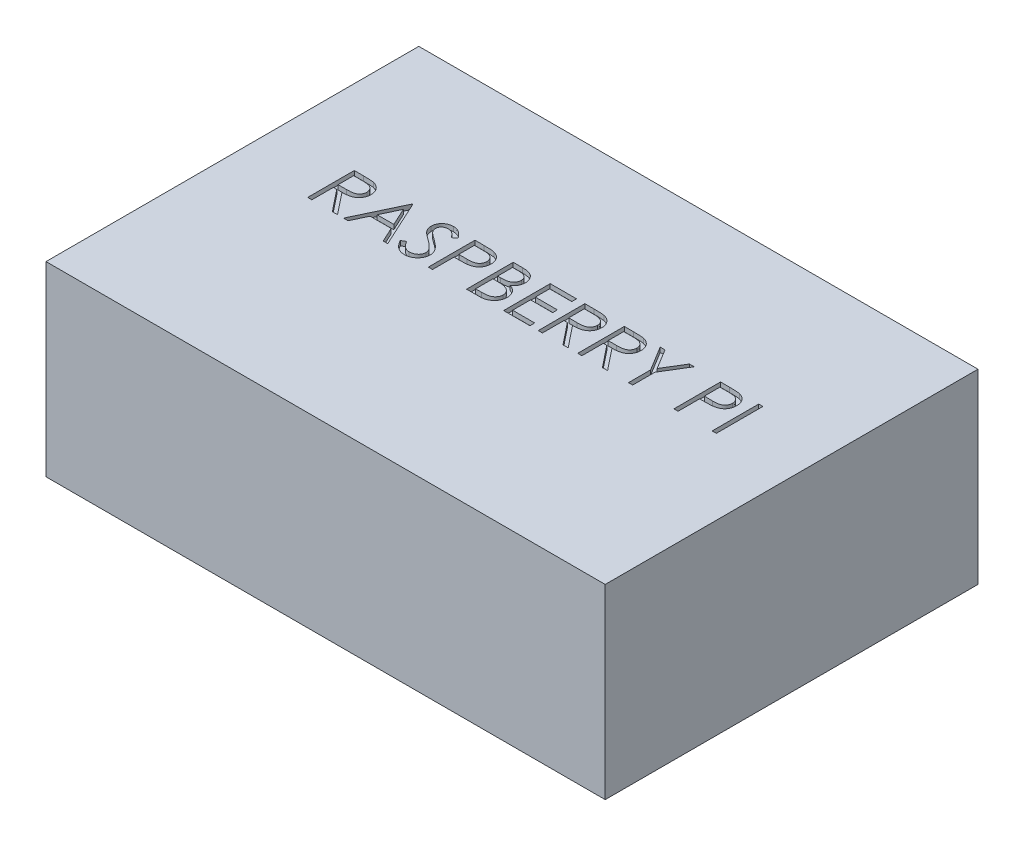
from build123d import *

# Parameters (mm, degrees)
SKETCH1_W           = 120
SKETCH1_H           = 80
BOSS_EXTRUDE1_DEPTH = 40
SKETCH2_W           = 0.897435897
SKETCH2_H           = 10
CUT_EXTRUDE1_DEPTH  = 1


with BuildPart() as part:
    # Sketch1 → Boss-Extrude1 (new body)
    with BuildSketch(Plane(origin=(0, 0, 0), x_dir=(1, 0, 0), z_dir=(0, 1, 0))):
        with Locations((60, 40)):
            Rectangle(SKETCH1_W, SKETCH1_H)
    extrude(amount=BOSS_EXTRUDE1_DEPTH)

    # Sketch2 → Cut-Extrude1 (cut)
    with BuildSketch(Plane(origin=(0, 40, 0), x_dir=(1, 0, 0), z_dir=(0, 1, 0))):
        with BuildLine():
            Line((16.153846154, 50), (18.155048077, 50))
            add(Edge.make_bspline(
                [(18.155048077, 50), (18.288594158, 49.999555469), (18.545017428, 49.998701919), (18.912369629, 49.993942596), (19.246161335, 49.98030158), (19.546218019, 49.96856277), (19.812534176, 49.947157224), (20.045926435, 49.926698232), (20.245319856, 49.899916344), (20.366022289, 49.875043707), (20.420673077, 49.863782051)],
                knots=[0, 0, 0, 0, 1.410062039, 2.707475311, 3.878576406, 4.937260626, 5.877586885, 6.699081471, 7.410979367, 8, 8, 8, 8], degree=3))
            add(Edge.make_bspline(
                [(20.420673077, 49.863782051), (20.49383486, 49.845705579), (20.638597687, 49.809938254), (20.847026447, 49.734339395), (21.045638801, 49.646854753), (21.233609728, 49.544101266), (21.409997703, 49.425316181), (21.576621448, 49.292550117), (21.734237058, 49.146529529), (21.876470287, 48.983572839), (22.010581863, 48.812611383), (22.123692225, 48.627743506), (22.221196452, 48.434424856), (22.298826501, 48.230689377), (22.361334997, 48.018512886), (22.405409966, 47.795973467), (22.431841931, 47.564084967), (22.434532947, 47.405919513), (22.435897436, 47.325721154)],
                knots=[0, 0, 0, 0, 1.027469482, 2.033020251, 3.019912614, 3.986113645, 4.951240523, 5.91722682, 6.890402269, 7.87763091, 8.8651537, 9.85103654, 10.82876324, 11.815024772, 12.821070561, 13.842952187, 14.906261191, 16, 16, 16, 16], degree=3))
            add(Edge.make_bspline(
                [(22.435897436, 47.325721154), (22.431700298, 47.192477998), (22.423510596, 46.93248609), (22.347153157, 46.555169286), (22.222077386, 46.203199815), (22.049725132, 45.87702085), (21.830240916, 45.582990434), (21.566455798, 45.324731991), (21.258222623, 45.108617955), (20.97128172, 44.958752798), (20.717812578, 44.862773059), (20.50914597, 44.795240606), (20.281526034, 44.743063562), (20.03713365, 44.696320328), (19.774951777, 44.661029773), (19.495608807, 44.63518236), (19.198905517, 44.619027935), (18.995079604, 44.616622207), (18.890224359, 44.615384615)],
                knots=[0, 0, 0, 0, 1.260483769, 2.459530307, 3.627416485, 4.787058657, 5.939039949, 7.08810263, 8.267026773, 9.491475466, 10.141966685, 10.831826277, 11.566392101, 12.351337768, 13.187381173, 14.07005841, 15.007169909, 16, 16, 16, 16], degree=3))
            Line((18.890224359, 44.615384615), (22.564102564, 40))
            Line((22.564102564, 40), (21.454326923, 40))
            Line((21.454326923, 40), (17.780448718, 44.615384615))
            Line((17.780448718, 44.615384615), (17.051282051, 44.615384615))
            Line((17.051282051, 44.615384615), (17.051282051, 40))
            Line((17.051282051, 40), (16.153846154, 40))
            Line((16.153846154, 40), (16.153846154, 50))
        make_face()
        with BuildLine():
            Line((17.051282051, 48.974358974), (17.051282051, 45.641025641))
            Line((17.051282051, 45.641025641), (18.882211538, 45.627003205))
            add(Edge.make_bspline(
                [(18.882211538, 45.627003205), (18.967697364, 45.626965386), (19.133393241, 45.626892082), (19.373109427, 45.638302871), (19.596309746, 45.651283781), (19.802140466, 45.671139054), (19.990693539, 45.69672783), (20.161874719, 45.728736356), (20.315963439, 45.766027964), (20.495673549, 45.823746895), (20.696349353, 45.915192661), (20.914439238, 46.048236943), (21.100160203, 46.215577284), (21.257068381, 46.406930015), (21.383152471, 46.617319298), (21.472044055, 46.84422321), (21.528451033, 47.08191349), (21.53510402, 47.245279512), (21.538461538, 47.327724359)],
                knots=[0, 0, 0, 0, 1.146690395, 2.22261258, 3.21895312, 4.145990853, 4.996080663, 5.770904154, 6.481378293, 7.121626537, 8.300444488, 9.431385265, 10.535395872, 11.636531494, 12.74115979, 13.810798291, 14.895190096, 16, 16, 16, 16], degree=3))
            add(Edge.make_bspline(
                [(21.538461538, 47.327724359), (21.535026907, 47.408143141), (21.52822072, 47.567503823), (21.47265281, 47.800806424), (21.378683149, 48.02099771), (21.252048183, 48.227181953), (21.097764884, 48.414341198), (20.916856847, 48.574475921), (20.714270575, 48.706617249), (20.524924294, 48.791058336), (20.355683687, 48.842829345), (20.208741801, 48.879261242), (20.042709008, 48.908531153), (19.856779126, 48.931982755), (19.651745895, 48.952139739), (19.426572607, 48.96571625), (19.182753234, 48.973755861), (19.013762002, 48.974153258), (18.926282051, 48.974358974)],
                knots=[0, 0, 0, 0, 1.101028733, 2.181837193, 3.264309656, 4.369019818, 5.486613113, 6.575447106, 7.666700264, 8.788928104, 9.402425223, 10.0903467, 10.862060571, 11.710948788, 12.657782767, 13.684531032, 14.801375019, 16, 16, 16, 16], degree=3))
            Line((18.926282051, 48.974358974), (17.051282051, 48.974358974))
        make_face(mode=Mode.SUBTRACT)
        Polygon((28.717948718, 50), (33.333333333, 40), (32.357772436, 40), (30.879407051, 43.205128205), (26.346153846, 43.205128205), (24.827724359, 40), (23.846153846, 40), (28.58974359, 50), align=None)
        Polygon((28.643830128, 48.048878205), (26.834935897, 44.230769231), (30.406650641, 44.230769231), align=None, mode=Mode.SUBTRACT)
        with BuildLine():
            Line((34.102564103, 41.929086538), (34.947916667, 42.435897436))
            add(Edge.make_bspline(
                [(34.947916667, 42.435897436), (35.026540202, 42.304284907), (35.177179861, 42.052120382), (35.428469458, 41.711383124), (35.688849204, 41.421776961), (35.9602473, 41.184986654), (36.241007152, 40.998561264), (36.532961591, 40.866554887), (36.835126765, 40.784223529), (37.040766255, 40.774223282), (37.143429487, 40.769230769)],
                knots=[0, 0, 0, 0, 1.272034388, 2.437168799, 3.508375237, 4.49857839, 5.41946034, 6.295179144, 7.148887113, 8, 8, 8, 8], degree=3))
            add(Edge.make_bspline(
                [(37.143429487, 40.769230769), (37.231106231, 40.771672691), (37.404925583, 40.776513806), (37.660817706, 40.823030383), (37.909337141, 40.894493608), (38.14536182, 40.996839127), (38.365635004, 41.120663372), (38.558796991, 41.270223879), (38.725785886, 41.437670181), (38.862383356, 41.624477766), (38.967183457, 41.825383905), (39.047732224, 42.031600909), (39.092432434, 42.246368247), (39.099166016, 42.390969569), (39.102564103, 42.463942308)],
                knots=[0, 0, 0, 0, 1.095163259, 2.171163733, 3.241058638, 4.321873601, 5.38011039, 6.391990106, 7.366004449, 8.327778327, 9.272591725, 10.192022065, 11.087607919, 12, 12, 12, 12], degree=3))
            add(Edge.make_bspline(
                [(39.102564103, 42.463942308), (39.098351786, 42.547201878), (39.089788763, 42.716456419), (39.017413105, 42.966169713), (38.903558114, 43.213291342), (38.79852199, 43.3661521), (38.743990385, 43.445512821)],
                knots=[0, 0, 0, 0, 0.938893495, 1.908633276, 2.914225137, 4, 4, 4, 4], degree=3))
            add(Edge.make_bspline(
                [(38.743990385, 43.445512821), (38.699217201, 43.502789459), (38.605221503, 43.623034598), (38.44362861, 43.802020985), (38.254011141, 43.986645039), (38.042858127, 44.183956631), (37.802477873, 44.384778907), (37.54039926, 44.598688272), (37.249931092, 44.817549921), (37.046218244, 44.96432868), (36.941105769, 45.040064103)],
                knots=[0, 0, 0, 0, 0.722233717, 1.516239348, 2.393582979, 3.351407094, 4.387010283, 5.505090956, 6.712668013, 8, 8, 8, 8], degree=3))
            add(Edge.make_bspline(
                [(36.941105769, 45.040064103), (36.835894352, 45.115002924), (36.634738133, 45.258280245), (36.353427898, 45.470921057), (36.101872289, 45.665332112), (35.881189385, 45.843343575), (35.691476251, 46.004979589), (35.531237934, 46.148687987), (35.404556342, 46.278355303), (35.334111826, 46.362473423), (35.302483974, 46.400240385)],
                knots=[0, 0, 0, 0, 1.452282411, 2.77665338, 3.964542531, 5.026858415, 5.96415736, 6.766646006, 7.446254459, 8, 8, 8, 8], degree=3))
            add(Edge.make_bspline(
                [(35.302483974, 46.400240385), (35.258276702, 46.45910049), (35.171337169, 46.574856786), (35.056577153, 46.755784951), (34.959036688, 46.940994281), (34.882572882, 47.130982466), (34.818183685, 47.323082262), (34.774875312, 47.519800107), (34.747757035, 47.720253303), (34.74497993, 47.855149019), (34.743589744, 47.922676282)],
                knots=[0, 0, 0, 0, 1.068054152, 2.10047183, 3.106115577, 4.101338837, 5.06977816, 6.043150881, 7.020423561, 8, 8, 8, 8], degree=3))
            add(Edge.make_bspline(
                [(34.743589744, 47.922676282), (34.747318912, 48.028475638), (34.754697541, 48.237812963), (34.817099019, 48.543615336), (34.915593001, 48.835576528), (35.053578395, 49.110806053), (35.231456546, 49.362137427), (35.437302187, 49.592461675), (35.682477862, 49.786086196), (35.951485357, 49.955263505), (36.245932134, 50.087680435), (36.554477572, 50.187568949), (36.877612064, 50.244166828), (37.096478163, 50.252289014), (37.207532051, 50.256410256)],
                knots=[0, 0, 0, 0, 1.005424448, 1.989358655, 2.955360095, 3.929531133, 4.905563448, 5.876582895, 6.856512386, 7.866279853, 8.892233794, 9.918561126, 10.94386622, 12, 12, 12, 12], degree=3))
            add(Edge.make_bspline(
                [(37.207532051, 50.256410256), (37.325372338, 50.252345823), (37.559719057, 50.244262963), (37.904431102, 50.173984302), (38.236318863, 50.057696668), (38.503299619, 49.925729074), (38.712250366, 49.793925029), (38.871601031, 49.673868388), (39.033079462, 49.535653792), (39.19798819, 49.378913089), (39.363532931, 49.202208086), (39.532171366, 49.006748975), (39.704297849, 48.793730244), (39.815028878, 48.641660242), (39.871794872, 48.563701923)],
                knots=[0, 0, 0, 0, 1.286793592, 2.559021753, 3.825965368, 5.121522368, 5.803751409, 6.523245864, 7.299691795, 8.125521123, 9.008227632, 9.944561021, 10.946284179, 12, 12, 12, 12], degree=3))
            Line((39.871794872, 48.563701923), (39.060496795, 47.948717949))
            add(Edge.make_bspline(
                [(39.060496795, 47.948717949), (39.011508416, 48.011828493), (38.917168253, 48.133364645), (38.773941148, 48.303568404), (38.638945011, 48.45904406), (38.505943869, 48.594087282), (38.381962065, 48.716093378), (38.261627658, 48.820549826), (38.146672369, 48.908480098), (38.00176691, 49.002318841), (37.819716286, 49.095337423), (37.59118904, 49.174049074), (37.352371111, 49.221349251), (37.189715021, 49.227603216), (37.107371795, 49.230769231)],
                knots=[0, 0, 0, 0, 1.181633172, 2.275549214, 3.290209073, 4.226197932, 5.078386478, 5.862611352, 6.581680152, 7.217281963, 8.414376989, 9.595101626, 10.782541182, 12, 12, 12, 12], degree=3))
            add(Edge.make_bspline(
                [(37.107371795, 49.230769231), (37.004067445, 49.227307231), (36.804854738, 49.22063109), (36.522025492, 49.147716847), (36.267471421, 49.032911531), (36.048749806, 48.872011594), (35.866644157, 48.681380186), (35.734914275, 48.462012029), (35.655628091, 48.219776593), (35.645953006, 48.050800432), (35.641025641, 47.96474359)],
                knots=[0, 0, 0, 0, 1.14458467, 2.207223713, 3.21896685, 4.227309161, 5.202851033, 6.127160689, 7.046193047, 8, 8, 8, 8], degree=3))
            add(Edge.make_bspline(
                [(35.641025641, 47.96474359), (35.64214886, 47.911167937), (35.644397135, 47.803929024), (35.675753699, 47.64549639), (35.716037496, 47.487463992), (35.779873587, 47.330542326), (35.868003026, 47.171987015), (35.9837321, 47.009067765), (36.12948442, 46.840348597), (36.241133027, 46.730613243), (36.300080128, 46.672676282)],
                knots=[0, 0, 0, 0, 0.858281714, 1.717966888, 2.583508476, 3.4729293, 4.427298488, 5.488583878, 6.674047936, 8, 8, 8, 8], degree=3))
            add(Edge.make_bspline(
                [(36.300080128, 46.672676282), (36.321969764, 46.653141923), (36.373974527, 46.606732756), (36.4690486, 46.530754811), (36.594599453, 46.437032605), (36.747348599, 46.321068843), (36.930112489, 46.18655038), (37.142911221, 46.035197203), (37.383372744, 45.862095891), (37.554006789, 45.741074346), (37.644230769, 45.677083333)],
                knots=[0, 0, 0, 0, 0.420754252, 0.999615792, 1.744751191, 2.668019286, 3.750313428, 4.999500688, 6.413464383, 8, 8, 8, 8], degree=3))
            add(Edge.make_bspline(
                [(37.644230769, 45.677083333), (37.75276195, 45.59810802), (37.96291754, 45.445183272), (38.261939197, 45.215424187), (38.533064363, 44.990716276), (38.777244944, 44.772494542), (38.996893254, 44.562414276), (39.189572456, 44.357948047), (39.357245828, 44.160560696), (39.537757881, 43.907496194), (39.722208794, 43.596693096), (39.880613101, 43.215898129), (39.980494094, 42.833622928), (39.993555566, 42.576689109), (40, 42.449919872)],
                knots=[0, 0, 0, 0, 1.163667725, 2.253281268, 3.268753668, 4.215851969, 5.092017293, 5.902905408, 6.650798638, 7.335211899, 8.59617414, 9.77448103, 10.901945474, 12, 12, 12, 12], degree=3))
            add(Edge.make_bspline(
                [(40, 42.449919872), (39.998122463, 42.3602674), (39.994403848, 42.182703447), (39.95165838, 41.921974656), (39.889030765, 41.6687436), (39.794638668, 41.426140421), (39.679429645, 41.189726814), (39.533240365, 40.965704241), (39.363789837, 40.749114531), (39.169407652, 40.545733127), (38.956705074, 40.35902971), (38.731894518, 40.192946677), (38.494608024, 40.054465753), (38.246132833, 39.941463347), (37.986411871, 39.853081869), (37.715532489, 39.7890451), (37.433048171, 39.749743068), (37.241046795, 39.74566375), (37.143429487, 39.743589744)],
                knots=[0, 0, 0, 0, 0.983748083, 1.948392443, 2.894712957, 3.844097841, 4.80183111, 5.778335162, 6.776009319, 7.81870978, 8.863265674, 9.881300176, 10.883814829, 11.87499822, 12.874611388, 13.892143829, 14.928324115, 16, 16, 16, 16], degree=3))
            add(Edge.make_bspline(
                [(37.143429487, 39.743589744), (37.067899936, 39.745050262), (36.91779205, 39.747952906), (36.695764959, 39.773613708), (36.478223275, 39.809919718), (36.267896755, 39.867559918), (36.062075579, 39.937494138), (35.861654909, 40.02360366), (35.666537612, 40.126795664), (35.475630233, 40.244781448), (35.289418305, 40.38208929), (35.109648397, 40.542013566), (34.930422153, 40.72014358), (34.757029592, 40.921316618), (34.585963465, 41.142282569), (34.420596581, 41.385108807), (34.257505959, 41.648472675), (34.155176051, 41.833801492), (34.102564103, 41.929086538)],
                knots=[0, 0, 0, 0, 0.915332311, 1.819136955, 2.706846663, 3.586547465, 4.459518054, 5.340707479, 6.227863349, 7.133153174, 8.059268498, 9.028702269, 10.047606654, 11.120612155, 12.245963614, 13.433783089, 14.680604001, 16, 16, 16, 16], degree=3))
        make_face()
        with BuildLine():
            Line((42.051282051, 50), (44.012419872, 50))
            add(Edge.make_bspline(
                [(44.012419872, 50), (44.147308175, 49.999851725), (44.405760155, 49.999567624), (44.776374599, 49.990954064), (45.112973833, 49.97944923), (45.414832064, 49.963500963), (45.682878058, 49.944653563), (45.915898914, 49.918219164), (46.115726218, 49.89061832), (46.235458931, 49.862557158), (46.290064103, 49.849759615)],
                knots=[0, 0, 0, 0, 1.415646017, 2.712440637, 3.8905458, 4.950247383, 5.884950622, 6.709939814, 7.411656543, 8, 8, 8, 8], degree=3))
            add(Edge.make_bspline(
                [(46.290064103, 49.849759615), (46.359188485, 49.830839759), (46.49580842, 49.793445868), (46.692668543, 49.718549515), (46.879965244, 49.629743329), (47.058341125, 49.528532072), (47.22560422, 49.410573318), (47.384250051, 49.280648696), (47.532878566, 49.1357585), (47.670653972, 48.977527814), (47.797181965, 48.808612929), (47.906123916, 48.626492272), (47.997344564, 48.434231405), (48.075582483, 48.231964059), (48.131892353, 48.017991706), (48.174312066, 47.793801099), (48.201236716, 47.55941627), (48.203815464, 47.39924522), (48.205128205, 47.317708333)],
                knots=[0, 0, 0, 0, 0.999701418, 1.975846123, 2.934577507, 3.890451536, 4.834027766, 5.787354733, 6.749476667, 7.726910423, 8.712836071, 9.690891519, 10.682875813, 11.679750201, 12.712814741, 13.765529915, 14.8625177, 16, 16, 16, 16], degree=3))
            add(Edge.make_bspline(
                [(48.205128205, 47.317708333), (48.203924134, 47.235486114), (48.201568289, 47.074612788), (48.173293188, 46.839261965), (48.135206926, 46.614352279), (48.07664392, 46.40038242), (47.999941996, 46.198623076), (47.909964703, 46.005990985), (47.80144033, 45.825763351), (47.676740817, 45.657285872), (47.538021976, 45.500400408), (47.385870724, 45.356243853), (47.220901317, 45.225660029), (47.043638036, 45.108356189), (46.852352754, 45.007052534), (46.649946601, 44.916317377), (46.434660268, 44.840114346), (46.285681657, 44.800028457), (46.209935897, 44.779647436)],
                knots=[0, 0, 0, 0, 1.121902311, 2.195077645, 3.232258892, 4.234102512, 5.217864754, 6.176164875, 7.132989551, 8.084763148, 9.034132444, 9.988522005, 10.94243251, 11.903244335, 12.886203696, 13.894208494, 14.929344452, 16, 16, 16, 16], degree=3))
            add(Edge.make_bspline(
                [(46.209935897, 44.779647436), (46.147286372, 44.766324633), (46.009986294, 44.737126935), (45.78386423, 44.704531344), (45.520591699, 44.676709628), (45.220528042, 44.655849235), (44.883942599, 44.637991039), (44.510653293, 44.623796485), (44.099927358, 44.615996903), (43.813438089, 44.615594638), (43.663862179, 44.615384615)],
                knots=[0, 0, 0, 0, 0.601384939, 1.31797006, 2.144135048, 3.087295005, 4.142315834, 5.309527816, 6.595305764, 8, 8, 8, 8], degree=3))
            Line((43.663862179, 44.615384615), (42.948717949, 44.615384615))
            Line((42.948717949, 44.615384615), (42.948717949, 40))
            Line((42.948717949, 40), (42.051282051, 40))
            Line((42.051282051, 40), (42.051282051, 50))
        make_face()
        with BuildLine():
            Line((42.948717949, 48.974358974), (42.948717949, 45.641025641))
            Line((42.948717949, 45.641025641), (44.699519231, 45.618990385))
            add(Edge.make_bspline(
                [(44.699519231, 45.618990385), (44.785004733, 45.618946203), (44.950032733, 45.618860911), (45.188421942, 45.630247264), (45.409591334, 45.643391643), (45.61286155, 45.662637139), (45.79832422, 45.689840731), (45.966288588, 45.71730284), (46.115452253, 45.757032447), (46.290021401, 45.81052693), (46.484545251, 45.901762975), (46.696166818, 46.034191232), (46.875511351, 46.202993256), (47.030706484, 46.39278706), (47.153866136, 46.603927429), (47.244026114, 46.829838677), (47.297000849, 47.068203962), (47.30410426, 47.23131293), (47.307692308, 47.313701923)],
                knots=[0, 0, 0, 0, 1.160613943, 2.240541288, 3.23993089, 4.169200891, 5.011653406, 5.7853311, 6.478053781, 7.106038997, 8.262395093, 9.384106736, 10.481365981, 11.59014053, 12.70357646, 13.786202915, 14.881775077, 16, 16, 16, 16], degree=3))
            add(Edge.make_bspline(
                [(47.307692308, 47.313701923), (47.304084746, 47.394097676), (47.296913361, 47.553914482), (47.243610895, 47.788139512), (47.154041426, 48.011670096), (47.029879728, 48.220164626), (46.879190785, 48.409275494), (46.704049805, 48.573553), (46.504869058, 48.705615008), (46.319588398, 48.790852956), (46.155013581, 48.8428966), (46.012065124, 48.87931043), (45.850663197, 48.90838359), (45.670755255, 48.931925027), (45.47373573, 48.952077773), (45.257911973, 48.965751994), (45.024101564, 48.973756154), (44.861785647, 48.974153169), (44.777644231, 48.974358974)],
                knots=[0, 0, 0, 0, 1.120700087, 2.227813068, 3.331159281, 4.466773991, 5.599788987, 6.693661531, 7.80175334, 8.91857717, 9.525282508, 10.207424825, 10.974604443, 11.810962634, 12.737642355, 13.736264703, 14.826523623, 16, 16, 16, 16], degree=3))
            Line((44.777644231, 48.974358974), (42.948717949, 48.974358974))
        make_face(mode=Mode.SUBTRACT)
        with BuildLine():
            Line((50.256410256, 50), (52.207532051, 50))
            add(Edge.make_bspline(
                [(52.207532051, 50), (52.303041989, 49.999497856), (52.488164018, 49.998524576), (52.757362424, 49.983429916), (53.009501883, 49.962848002), (53.244655518, 49.930190594), (53.462714668, 49.890785516), (53.664336488, 49.843066042), (53.848879838, 49.785847146), (54.069201942, 49.694857771), (54.32040383, 49.559648718), (54.592399238, 49.359852818), (54.824982779, 49.115474352), (55.025515114, 48.839809622), (55.184946884, 48.53656456), (55.300287733, 48.212966878), (55.373310234, 47.873190472), (55.380820047, 47.63992425), (55.384615385, 47.522035256)],
                knots=[0, 0, 0, 0, 1.001505555, 1.941167018, 2.826882275, 3.653841531, 4.429895133, 5.150066043, 5.825578002, 6.45369114, 7.647487171, 8.808567382, 9.977351308, 11.170798116, 12.373658725, 13.556498008, 14.765093433, 16, 16, 16, 16], degree=3))
            add(Edge.make_bspline(
                [(55.384615385, 47.522035256), (55.381491903, 47.411599383), (55.375353968, 47.194582477), (55.31666037, 46.877170736), (55.224772746, 46.575024397), (55.097043463, 46.289246153), (54.931037759, 46.026292972), (54.734299706, 45.784043641), (54.496937413, 45.572754907), (54.319099584, 45.454632328), (54.228766026, 45.39463141)],
                knots=[0, 0, 0, 0, 1.044552857, 2.05264487, 3.044412934, 4.028983338, 5.005914585, 5.980388656, 6.974128949, 8, 8, 8, 8], degree=3))
            add(Edge.make_bspline(
                [(54.228766026, 45.39463141), (54.342367247, 45.351017128), (54.559714526, 45.267572201), (54.858817418, 45.120042304), (55.116516975, 44.959579131), (55.334794535, 44.784345273), (55.521473549, 44.595462957), (55.684481954, 44.390162631), (55.823571594, 44.165766179), (55.942751376, 43.924613221), (56.035747822, 43.669166169), (56.105393263, 43.401821094), (56.14530026, 43.123536651), (56.150979235, 42.934149853), (56.153846154, 42.838541667)],
                knots=[0, 0, 0, 0, 1.27268992, 2.434971085, 3.483601985, 4.442670788, 5.356604649, 6.2567628, 7.179492994, 8.113709626, 9.066344395, 10.018646069, 10.999752585, 12, 12, 12, 12], degree=3))
            add(Edge.make_bspline(
                [(56.153846154, 42.838541667), (56.151055165, 42.740922032), (56.145563817, 42.548852666), (56.105049612, 42.266695139), (56.036452163, 41.997052434), (55.941963174, 41.738180484), (55.818642275, 41.490580099), (55.668562377, 41.253970774), (55.489615052, 41.030729829), (55.289435426, 40.81837662), (55.062972154, 40.627440085), (54.818641425, 40.457395209), (54.553366226, 40.317549317), (54.271503386, 40.20007497), (53.969891054, 40.110340117), (53.649883604, 40.047561334), (53.311757027, 40.005261229), (53.079729167, 40.0017835), (52.960737179, 40)],
                knots=[0, 0, 0, 0, 0.978564426, 1.925352924, 2.850884081, 3.763762016, 4.682927383, 5.618979971, 6.567305752, 7.547517671, 8.540179244, 9.531824382, 10.526200242, 11.540722885, 12.589160233, 13.674978461, 14.80764778, 16, 16, 16, 16], degree=3))
            Line((52.960737179, 40), (50.256410256, 40))
            Line((50.256410256, 40), (50.256410256, 50))
        make_face()
        with BuildLine():
            Line((51.153846154, 48.974358974), (51.153846154, 45.769230769))
            Line((51.153846154, 45.769230769), (51.756810897, 45.769230769))
            add(Edge.make_bspline(
                [(51.756810897, 45.769230769), (51.844950313, 45.770373406), (52.015253625, 45.772581214), (52.261881901, 45.778905549), (52.490810524, 45.796614244), (52.701644333, 45.81431785), (52.894051316, 45.843102386), (53.067605206, 45.877365595), (53.225029768, 45.913602466), (53.406571327, 45.975229572), (53.612494037, 46.066308644), (53.832017192, 46.207656747), (54.025544248, 46.376012042), (54.188964784, 46.570271932), (54.322711843, 46.784175321), (54.415608172, 47.014309265), (54.478600412, 47.254938213), (54.484290502, 47.420133221), (54.487179487, 47.50400641)],
                knots=[0, 0, 0, 0, 1.156816544, 2.235205308, 3.236616184, 4.169592532, 5.011045266, 5.787822928, 6.49130361, 7.128639758, 8.301311294, 9.436451833, 10.541879658, 11.654887649, 12.756523258, 13.837046038, 14.901820046, 16, 16, 16, 16], degree=3))
            add(Edge.make_bspline(
                [(54.487179487, 47.50400641), (54.485676115, 47.559508615), (54.482727087, 47.668382249), (54.458574794, 47.82709469), (54.417524581, 47.976362554), (54.364798029, 48.118231441), (54.291116061, 48.248265298), (54.204363309, 48.370960143), (54.099547051, 48.482137625), (53.980240443, 48.586050477), (53.84307295, 48.678177699), (53.688126401, 48.758865594), (53.513304467, 48.823839242), (53.321553453, 48.880742534), (53.109921774, 48.920709088), (52.880851622, 48.954004482), (52.63246671, 48.970955173), (52.46062356, 48.973199067), (52.371794872, 48.974358974)],
                knots=[0, 0, 0, 0, 0.91205012, 1.789085906, 2.630437955, 3.453916878, 4.269457761, 5.079663411, 5.91843418, 6.774407191, 7.675494373, 8.627863946, 9.638891023, 10.736472738, 11.911756761, 13.175263542, 14.539845004, 16, 16, 16, 16], degree=3))
            Line((52.371794872, 48.974358974), (51.153846154, 48.974358974))
        make_face(mode=Mode.SUBTRACT)
        with BuildLine():
            Line((51.153846154, 44.743589744), (51.153846154, 41.025641026))
            Line((51.153846154, 41.025641026), (52.431891026, 41.025641026))
            add(Edge.make_bspline(
                [(52.431891026, 41.025641026), (52.523373671, 41.026737447), (52.69969441, 41.028850654), (52.954269353, 41.035749381), (53.190221078, 41.051441598), (53.406472895, 41.076144025), (53.605359902, 41.102939594), (53.784496197, 41.138971825), (53.945333892, 41.18025457), (54.131831914, 41.24406649), (54.341841938, 41.343199265), (54.56815867, 41.492668483), (54.769376437, 41.670735076), (54.940248606, 41.876823403), (55.080285716, 42.100912908), (55.182158445, 42.338471051), (55.244989464, 42.585572558), (55.252595662, 42.754048879), (55.256410256, 42.838541667)],
                knots=[0, 0, 0, 0, 1.160039823, 2.235823828, 3.228722157, 4.157150951, 4.99529583, 5.772374946, 6.472645482, 7.099169577, 8.269452708, 9.405989375, 10.527446681, 11.663510218, 12.788923519, 13.866172445, 14.929861265, 16, 16, 16, 16], degree=3))
            add(Edge.make_bspline(
                [(55.256410256, 42.838541667), (55.255621387, 42.891379782), (55.254056372, 42.99620373), (55.230454615, 43.150248928), (55.196129273, 43.299465709), (55.151753748, 43.444259253), (55.087126699, 43.582011757), (55.011679427, 43.715447641), (54.92321828, 43.844743297), (54.785377806, 44.008206878), (54.584886422, 44.196541201), (54.30000992, 44.380934064), (53.976089069, 44.529642085), (53.741153375, 44.592783446), (53.619791667, 44.625400641)],
                knots=[0, 0, 0, 0, 0.723448775, 1.435228256, 2.130040452, 2.821711965, 3.505591119, 4.210454504, 4.921174351, 5.648778258, 7.137944449, 8.670945889, 10.280296675, 12, 12, 12, 12], degree=3))
            add(Edge.make_bspline(
                [(53.619791667, 44.625400641), (53.571137107, 44.635272309), (53.465643986, 44.656676123), (53.293622328, 44.679269561), (53.097234131, 44.699398304), (52.87602591, 44.714287326), (52.629717793, 44.72967745), (52.357783739, 44.735662653), (52.061334269, 44.742803396), (51.855641776, 44.743320923), (51.748798077, 44.743589744)],
                knots=[0, 0, 0, 0, 0.634451884, 1.375622551, 2.216452059, 3.157844607, 4.20941857, 5.370758133, 6.634282058, 8, 8, 8, 8], degree=3))
            Line((51.748798077, 44.743589744), (51.153846154, 44.743589744))
        make_face(mode=Mode.SUBTRACT)
        Polygon((58.205128205, 50), (63.846153846, 50), (63.846153846, 48.974358974), (59.102564103, 48.974358974), (59.102564103, 45.897435897), (63.846153846, 45.897435897), (63.846153846, 44.871794872), (59.102564103, 44.871794872), (59.102564103, 41.025641026), (63.846153846, 41.025641026), (63.846153846, 40), (58.205128205, 40), align=None)
        with BuildLine():
            Line((65.641025641, 50), (67.642227564, 50))
            add(Edge.make_bspline(
                [(67.642227564, 50), (67.775773646, 49.999555469), (68.032196915, 49.998701919), (68.399549116, 49.993942596), (68.733340822, 49.98030158), (69.033397506, 49.96856277), (69.299713663, 49.947157224), (69.533105922, 49.926698232), (69.732499344, 49.899916344), (69.853201776, 49.875043707), (69.907852564, 49.863782051)],
                knots=[0, 0, 0, 0, 1.410062039, 2.707475311, 3.878576406, 4.937260626, 5.877586885, 6.699081471, 7.410979367, 8, 8, 8, 8], degree=3))
            add(Edge.make_bspline(
                [(69.907852564, 49.863782051), (69.981014347, 49.845705579), (70.125777174, 49.809938254), (70.334205935, 49.734339395), (70.532818289, 49.646854753), (70.720789215, 49.544101266), (70.89717719, 49.425316181), (71.063800935, 49.292550117), (71.221416545, 49.146529529), (71.363649774, 48.983572839), (71.49776135, 48.812611383), (71.610871712, 48.627743506), (71.708375939, 48.434424856), (71.786005988, 48.230689377), (71.848514484, 48.018512886), (71.892589453, 47.795973467), (71.919021418, 47.564084967), (71.921712434, 47.405919513), (71.923076923, 47.325721154)],
                knots=[0, 0, 0, 0, 1.027469482, 2.033020251, 3.019912614, 3.986113645, 4.951240523, 5.91722682, 6.890402269, 7.87763091, 8.8651537, 9.85103654, 10.82876324, 11.815024772, 12.821070561, 13.842952187, 14.906261191, 16, 16, 16, 16], degree=3))
            add(Edge.make_bspline(
                [(71.923076923, 47.325721154), (71.918879786, 47.192477998), (71.910690083, 46.93248609), (71.834332644, 46.555169286), (71.709256874, 46.203199815), (71.536904619, 45.87702085), (71.317420403, 45.582990434), (71.053635286, 45.324731991), (70.74540211, 45.108617955), (70.458461207, 44.958752798), (70.204992065, 44.862773059), (69.996325457, 44.795240606), (69.768705522, 44.743063562), (69.524313137, 44.696320328), (69.262131264, 44.661029773), (68.982788294, 44.63518236), (68.686085004, 44.619027935), (68.482259092, 44.616622207), (68.377403846, 44.615384615)],
                knots=[0, 0, 0, 0, 1.260483769, 2.459530307, 3.627416485, 4.787058657, 5.939039949, 7.08810263, 8.267026773, 9.491475466, 10.141966685, 10.831826277, 11.566392101, 12.351337768, 13.187381173, 14.07005841, 15.007169909, 16, 16, 16, 16], degree=3))
            Line((68.377403846, 44.615384615), (72.051282051, 40))
            Line((72.051282051, 40), (70.94150641, 40))
            Line((70.94150641, 40), (67.267628205, 44.615384615))
            Line((67.267628205, 44.615384615), (66.538461538, 44.615384615))
            Line((66.538461538, 44.615384615), (66.538461538, 40))
            Line((66.538461538, 40), (65.641025641, 40))
            Line((65.641025641, 40), (65.641025641, 50))
        make_face()
        with BuildLine():
            Line((66.538461538, 48.974358974), (66.538461538, 45.641025641))
            Line((66.538461538, 45.641025641), (68.369391026, 45.627003205))
            add(Edge.make_bspline(
                [(68.369391026, 45.627003205), (68.454876851, 45.626965386), (68.620572729, 45.626892082), (68.860288914, 45.638302871), (69.083489233, 45.651283781), (69.289319953, 45.671139054), (69.477873026, 45.69672783), (69.649054206, 45.728736356), (69.803142926, 45.766027964), (69.982853036, 45.823746895), (70.18352884, 45.915192661), (70.401618725, 46.048236943), (70.58733969, 46.215577284), (70.744247868, 46.406930015), (70.870331958, 46.617319298), (70.959223542, 46.84422321), (71.01563052, 47.08191349), (71.022283507, 47.245279512), (71.025641026, 47.327724359)],
                knots=[0, 0, 0, 0, 1.146690395, 2.22261258, 3.21895312, 4.145990853, 4.996080663, 5.770904154, 6.481378293, 7.121626537, 8.300444488, 9.431385265, 10.535395872, 11.636531494, 12.74115979, 13.810798291, 14.895190096, 16, 16, 16, 16], degree=3))
            add(Edge.make_bspline(
                [(71.025641026, 47.327724359), (71.022206394, 47.408143141), (71.015400207, 47.567503823), (70.959832297, 47.800806424), (70.865862636, 48.02099771), (70.739227671, 48.227181953), (70.584944371, 48.414341198), (70.404036334, 48.574475921), (70.201450063, 48.706617249), (70.012103782, 48.791058336), (69.842863174, 48.842829345), (69.695921289, 48.879261242), (69.529888495, 48.908531153), (69.343958613, 48.931982755), (69.138925383, 48.952139739), (68.913752094, 48.96571625), (68.669932722, 48.973755861), (68.50094149, 48.974153258), (68.413461538, 48.974358974)],
                knots=[0, 0, 0, 0, 1.101028733, 2.181837193, 3.264309656, 4.369019818, 5.486613113, 6.575447106, 7.666700264, 8.788928104, 9.402425223, 10.0903467, 10.862060571, 11.710948788, 12.657782767, 13.684531032, 14.801375019, 16, 16, 16, 16], degree=3))
            Line((68.413461538, 48.974358974), (66.538461538, 48.974358974))
        make_face(mode=Mode.SUBTRACT)
        with BuildLine():
            Line((74.102564103, 50), (76.103766026, 50))
            add(Edge.make_bspline(
                [(76.103766026, 50), (76.237312107, 49.999555469), (76.493735377, 49.998701919), (76.861087578, 49.993942596), (77.194879284, 49.98030158), (77.494935967, 49.96856277), (77.761252124, 49.947157224), (77.994644384, 49.926698232), (78.194037805, 49.899916344), (78.314740237, 49.875043707), (78.369391026, 49.863782051)],
                knots=[0, 0, 0, 0, 1.410062039, 2.707475311, 3.878576406, 4.937260626, 5.877586885, 6.699081471, 7.410979367, 8, 8, 8, 8], degree=3))
            add(Edge.make_bspline(
                [(78.369391026, 49.863782051), (78.442552809, 49.845705579), (78.587315636, 49.809938254), (78.795744396, 49.734339395), (78.99435675, 49.646854753), (79.182327677, 49.544101266), (79.358715652, 49.425316181), (79.525339397, 49.292550117), (79.682955006, 49.146529529), (79.825188236, 48.983572839), (79.959299812, 48.812611383), (80.072410173, 48.627743506), (80.169914401, 48.434424856), (80.24754445, 48.230689377), (80.310052945, 48.018512886), (80.354127915, 47.795973467), (80.38055988, 47.564084967), (80.383250895, 47.405919513), (80.384615385, 47.325721154)],
                knots=[0, 0, 0, 0, 1.027469482, 2.033020251, 3.019912614, 3.986113645, 4.951240523, 5.91722682, 6.890402269, 7.87763091, 8.8651537, 9.85103654, 10.82876324, 11.815024772, 12.821070561, 13.842952187, 14.906261191, 16, 16, 16, 16], degree=3))
            add(Edge.make_bspline(
                [(80.384615385, 47.325721154), (80.380418247, 47.192477998), (80.372228545, 46.93248609), (80.295871106, 46.555169286), (80.170795335, 46.203199815), (79.998443081, 45.87702085), (79.778958865, 45.582990434), (79.515173747, 45.324731991), (79.206940571, 45.108617955), (78.919999669, 44.958752798), (78.666530527, 44.862773059), (78.457863919, 44.795240606), (78.230243983, 44.743063562), (77.985851598, 44.696320328), (77.723669726, 44.661029773), (77.444326756, 44.63518236), (77.147623466, 44.619027935), (76.943797553, 44.616622207), (76.838942308, 44.615384615)],
                knots=[0, 0, 0, 0, 1.260483769, 2.459530307, 3.627416485, 4.787058657, 5.939039949, 7.08810263, 8.267026773, 9.491475466, 10.141966685, 10.831826277, 11.566392101, 12.351337768, 13.187381173, 14.07005841, 15.007169909, 16, 16, 16, 16], degree=3))
            Line((76.838942308, 44.615384615), (80.512820513, 40))
            Line((80.512820513, 40), (79.403044872, 40))
            Line((79.403044872, 40), (75.729166667, 44.615384615))
            Line((75.729166667, 44.615384615), (75, 44.615384615))
            Line((75, 44.615384615), (75, 40))
            Line((75, 40), (74.102564103, 40))
            Line((74.102564103, 40), (74.102564103, 50))
        make_face()
        with BuildLine():
            Line((75, 48.974358974), (75, 45.641025641))
            Line((75, 45.641025641), (76.830929487, 45.627003205))
            add(Edge.make_bspline(
                [(76.830929487, 45.627003205), (76.916415313, 45.626965386), (77.08211119, 45.626892082), (77.321827375, 45.638302871), (77.545027694, 45.651283781), (77.750858415, 45.671139054), (77.939411487, 45.69672783), (78.110592668, 45.728736356), (78.264681388, 45.766027964), (78.444391497, 45.823746895), (78.645067301, 45.915192661), (78.863157187, 46.048236943), (79.048878152, 46.215577284), (79.20578633, 46.406930015), (79.33187042, 46.617319298), (79.420762003, 46.84422321), (79.477168981, 47.08191349), (79.483821968, 47.245279512), (79.487179487, 47.327724359)],
                knots=[0, 0, 0, 0, 1.146690395, 2.22261258, 3.21895312, 4.145990853, 4.996080663, 5.770904154, 6.481378293, 7.121626537, 8.300444488, 9.431385265, 10.535395872, 11.636531494, 12.74115979, 13.810798291, 14.895190096, 16, 16, 16, 16], degree=3))
            add(Edge.make_bspline(
                [(79.487179487, 47.327724359), (79.483744855, 47.408143141), (79.476938669, 47.567503823), (79.421370759, 47.800806424), (79.327401098, 48.02099771), (79.200766132, 48.227181953), (79.046482832, 48.414341198), (78.865574796, 48.574475921), (78.662988524, 48.706617249), (78.473642243, 48.791058336), (78.304401636, 48.842829345), (78.15745975, 48.879261242), (77.991426957, 48.908531153), (77.805497075, 48.931982755), (77.600463844, 48.952139739), (77.375290555, 48.96571625), (77.131471183, 48.973755861), (76.962479951, 48.974153258), (76.875, 48.974358974)],
                knots=[0, 0, 0, 0, 1.101028733, 2.181837193, 3.264309656, 4.369019818, 5.486613113, 6.575447106, 7.666700264, 8.788928104, 9.402425223, 10.0903467, 10.862060571, 11.710948788, 12.657782767, 13.684531032, 14.801375019, 16, 16, 16, 16], degree=3))
            Line((76.875, 48.974358974), (75, 48.974358974))
        make_face(mode=Mode.SUBTRACT)
        Polygon((81.794871795, 50), (82.822516026, 50), (85.446714744, 45.70713141), (88.072916667, 50), (89.102564103, 50), (85.897435897, 44.753605769), (85.897435897, 40), (85, 40), (85, 44.753605769), align=None)
        with BuildLine():
            Line((94.743589744, 50), (96.704727564, 50))
            add(Edge.make_bspline(
                [(96.704727564, 50), (96.839615867, 49.999851725), (97.098067847, 49.999567624), (97.468682292, 49.990954064), (97.805281525, 49.97944923), (98.107139756, 49.963500963), (98.375185751, 49.944653563), (98.608206607, 49.918219164), (98.80803391, 49.89061832), (98.927766623, 49.862557158), (98.982371795, 49.849759615)],
                knots=[0, 0, 0, 0, 1.415646017, 2.712440637, 3.8905458, 4.950247383, 5.884950622, 6.709939814, 7.411656543, 8, 8, 8, 8], degree=3))
            add(Edge.make_bspline(
                [(98.982371795, 49.849759615), (99.051496177, 49.830839759), (99.188116112, 49.793445868), (99.384976235, 49.718549515), (99.572272937, 49.629743329), (99.750648818, 49.528532072), (99.917911912, 49.410573318), (100.076557744, 49.280648696), (100.225186259, 49.1357585), (100.362961664, 48.977527814), (100.489489657, 48.808612929), (100.598431608, 48.626492272), (100.689652257, 48.434231405), (100.767890175, 48.231964059), (100.824200045, 48.017991706), (100.866619758, 47.793801099), (100.893544409, 47.55941627), (100.896123157, 47.39924522), (100.897435897, 47.317708333)],
                knots=[0, 0, 0, 0, 0.999701418, 1.975846123, 2.934577507, 3.890451536, 4.834027766, 5.787354733, 6.749476667, 7.726910423, 8.712836071, 9.690891519, 10.682875813, 11.679750201, 12.712814741, 13.765529915, 14.8625177, 16, 16, 16, 16], degree=3))
            add(Edge.make_bspline(
                [(100.897435897, 47.317708333), (100.896231827, 47.235486114), (100.893875981, 47.074612788), (100.86560088, 46.839261965), (100.827514619, 46.614352279), (100.768951612, 46.40038242), (100.692249689, 46.198623076), (100.602272395, 46.005990985), (100.493748022, 45.825763351), (100.369048509, 45.657285872), (100.230329668, 45.500400408), (100.078178416, 45.356243853), (99.913209009, 45.225660029), (99.735945729, 45.108356189), (99.544660446, 45.007052534), (99.342254293, 44.916317377), (99.126967961, 44.840114346), (98.977989349, 44.800028457), (98.90224359, 44.779647436)],
                knots=[0, 0, 0, 0, 1.121902311, 2.195077645, 3.232258892, 4.234102512, 5.217864754, 6.176164875, 7.132989551, 8.084763148, 9.034132444, 9.988522005, 10.94243251, 11.903244335, 12.886203696, 13.894208494, 14.929344452, 16, 16, 16, 16], degree=3))
            add(Edge.make_bspline(
                [(98.90224359, 44.779647436), (98.839594064, 44.766324633), (98.702293986, 44.737126935), (98.476171923, 44.704531344), (98.212899391, 44.676709628), (97.912835734, 44.655849235), (97.576250292, 44.637991039), (97.202960985, 44.623796485), (96.79223505, 44.615996903), (96.505745782, 44.615594638), (96.356169872, 44.615384615)],
                knots=[0, 0, 0, 0, 0.601384939, 1.31797006, 2.144135048, 3.087295005, 4.142315834, 5.309527816, 6.595305764, 8, 8, 8, 8], degree=3))
            Line((96.356169872, 44.615384615), (95.641025641, 44.615384615))
            Line((95.641025641, 44.615384615), (95.641025641, 40))
            Line((95.641025641, 40), (94.743589744, 40))
            Line((94.743589744, 40), (94.743589744, 50))
        make_face()
        with BuildLine():
            Line((95.641025641, 48.974358974), (95.641025641, 45.641025641))
            Line((95.641025641, 45.641025641), (97.391826923, 45.618990385))
            add(Edge.make_bspline(
                [(97.391826923, 45.618990385), (97.477312425, 45.618946203), (97.642340425, 45.618860911), (97.880729634, 45.630247264), (98.101899027, 45.643391643), (98.305169242, 45.662637139), (98.490631912, 45.689840731), (98.65859628, 45.71730284), (98.807759946, 45.757032447), (98.982329094, 45.81052693), (99.176852944, 45.901762975), (99.388474511, 46.034191232), (99.567819043, 46.202993256), (99.723014177, 46.39278706), (99.846173828, 46.603927429), (99.936333806, 46.829838677), (99.989308541, 47.068203962), (99.996411952, 47.23131293), (100, 47.313701923)],
                knots=[0, 0, 0, 0, 1.160613943, 2.240541288, 3.23993089, 4.169200891, 5.011653406, 5.7853311, 6.478053781, 7.106038997, 8.262395093, 9.384106736, 10.481365981, 11.59014053, 12.70357646, 13.786202915, 14.881775077, 16, 16, 16, 16], degree=3))
            add(Edge.make_bspline(
                [(100, 47.313701923), (99.996392439, 47.394097676), (99.989221053, 47.553914482), (99.935918587, 47.788139512), (99.846349119, 48.011670096), (99.72218742, 48.220164626), (99.571498477, 48.409275494), (99.396357497, 48.573553), (99.19717675, 48.705615008), (99.01189609, 48.790852956), (98.847321273, 48.8428966), (98.704372816, 48.87931043), (98.542970889, 48.90838359), (98.363062948, 48.931925027), (98.166043422, 48.952077773), (97.950219665, 48.965751994), (97.716409256, 48.973756154), (97.554093339, 48.974153169), (97.469951923, 48.974358974)],
                knots=[0, 0, 0, 0, 1.120700087, 2.227813068, 3.331159281, 4.466773991, 5.599788987, 6.693661531, 7.80175334, 8.91857717, 9.525282508, 10.207424825, 10.974604443, 11.810962634, 12.737642355, 13.736264703, 14.826523623, 16, 16, 16, 16], degree=3))
            Line((97.469951923, 48.974358974), (95.641025641, 48.974358974))
        make_face(mode=Mode.SUBTRACT)
        with Locations((103.397435898, 45)):
            Rectangle(SKETCH2_W, SKETCH2_H)
    extrude(amount=-CUT_EXTRUDE1_DEPTH, mode=Mode.SUBTRACT)


solid = part.part
